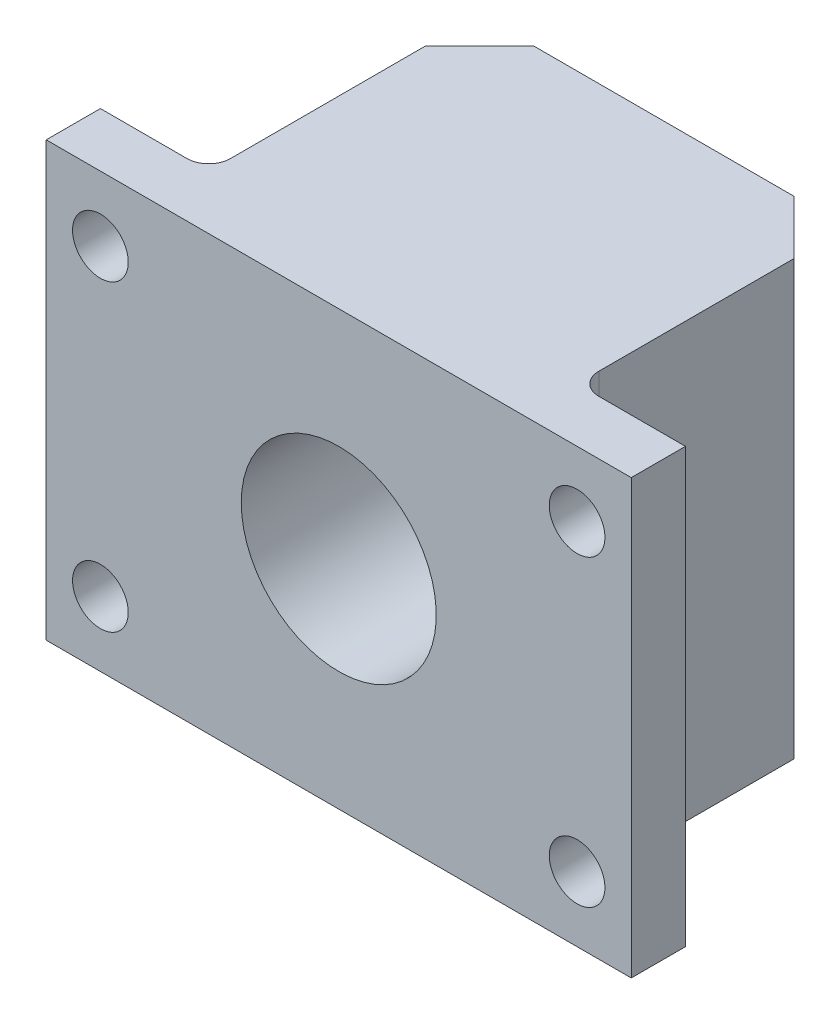
from build123d import *

# Parameters (mm, degrees)
BOSS_EXTRUDE4_DEPTH = 25.4
CHAMFER1_SIZE       = 3.175
SKETCH10_R          = 1.63195
CUT_EXTRUDE3_DEPTH  = 3.175
SKETCH11_R          = 5.715
CUT_EXTRUDE4_DEPTH  = 20.05
FILLET1_R           = 1.27


with BuildPart() as part:
    # Sketch4 → Boss-Extrude4 (new body)
    with BuildSketch(Plane(origin=(0, 0, 0), x_dir=(1, 0, 0), z_dir=(0, 1, 0))):
        Polygon((-10.795, 3.175), (-17.145, 3.175), (-17.145, 0), (-12.7, 0), (12.7, 0), (17.145, 0), (17.145, 3.175), (10.795, 3.175), (10.795, 19.05), (-10.795, 19.05), align=None)
    extrude(amount=BOSS_EXTRUDE4_DEPTH)

    # Chamfer1
    chamfer1_edges = [part.edges().sort_by_distance(p)[0] for p in [
        (-10.795, 12.7, -19.05),
        (10.795, 12.7, -19.05),
    ]]
    chamfer(chamfer1_edges, length=CHAMFER1_SIZE)

    # Sketch10 → Cut-Extrude3 (cut)
    with BuildSketch(Plane(origin=(0, 0, -3.175), x_dir=(-1, 0, 0), z_dir=(0, 0, -1))):
        with Locations((-13.97, 21.59)):
            Circle(SKETCH10_R)
        with Locations((-13.97, 3.81)):
            Circle(SKETCH10_R)
        with Locations((13.97, 3.81)):
            Circle(SKETCH10_R)
        with Locations((13.97, 21.59)):
            Circle(SKETCH10_R)
    extrude(amount=-CUT_EXTRUDE3_DEPTH, mode=Mode.SUBTRACT)

    # Sketch11 → Cut-Extrude4 (cut, through all)
    with BuildSketch(Plane(origin=(0, 0, -19.05), x_dir=(-1, 0, 0), z_dir=(0, 0, -1))):
        with Locations((0, 12.7)):
            Circle(SKETCH11_R)
    extrude(amount=-CUT_EXTRUDE4_DEPTH, mode=Mode.SUBTRACT)

    # Fillet1
    fillet1_edges = [part.edges().sort_by_distance(p)[0] for p in [
        (-10.795, 12.7, -3.175),
        (10.795, 12.7, -3.175),
    ]]
    fillet(fillet1_edges, radius=FILLET1_R)


solid = part.part
